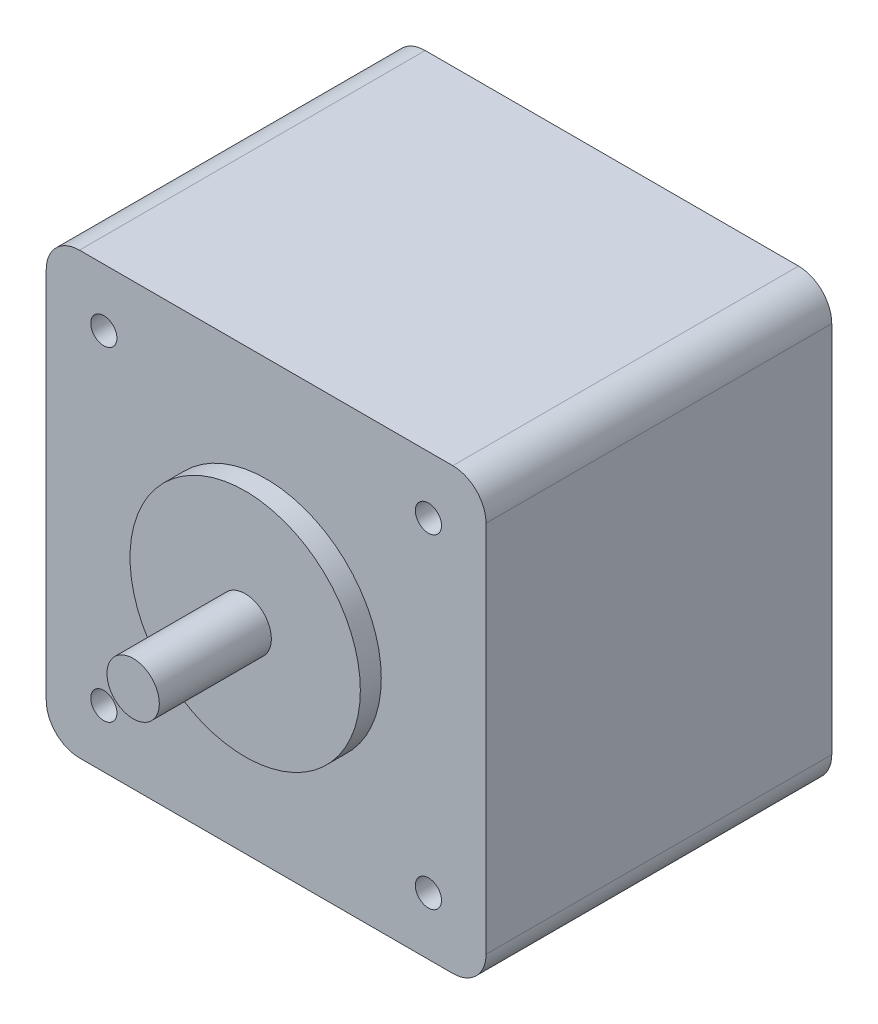
from build123d import *

# Parameters (mm, degrees)
SKETCH1_W                 = 42
SKETCH1_H                 = 42
BOSS_EXTRUDE1_DEPTH       = 33.02
M3X0_5_TAPPED_HOLE1_D     = 2.5
M3X0_5_TAPPED_HOLE1_DEPTH = 7.5
M3X0_5_TAPPED_HOLE1_TIP   = 0.751075774
FILLET1_R                 = 3.175


with BuildPart() as part:
    # Sketch1 → Boss-Extrude1 (new body)
    with BuildSketch(Plane.XY.offset(33.02)):
        Rectangle(SKETCH1_W, SKETCH1_H)
    extrude(amount=-BOSS_EXTRUDE1_DEPTH)

    # Sketch6 → Revolve5 (revolve)
    with BuildSketch(Plane(origin=(0, 0, 0), x_dir=(1, 0, 0), z_dir=(0, 1, 0))):
        Polygon((10.9982, -33.02), (0, -33.02), (0, -45.72), (2.5, -45.72), (2.5, -35.02), (10.9982, -35.02), align=None)
    revolve(axis=Axis((0, 0, 33.02), (0, 0, 1)))

    # M3x0.5 Tapped Hole1
    with Locations(Plane.XY.offset(33.02)):
        with Locations((-15.5, 15.5), (-15.5, -15.5), (15.5, -15.5), (15.5, 15.5)):
            Hole(M3X0_5_TAPPED_HOLE1_D / 2, depth=M3X0_5_TAPPED_HOLE1_DEPTH)
            with Locations((0, 0, -(M3X0_5_TAPPED_HOLE1_DEPTH + M3X0_5_TAPPED_HOLE1_TIP / 2))):  # 118° drill point
                Cone(0, M3X0_5_TAPPED_HOLE1_D / 2, M3X0_5_TAPPED_HOLE1_TIP, mode=Mode.SUBTRACT)

    # Fillet1
    fillet1_edges = [part.edges().sort_by_distance(p)[0] for p in [
        (-21, -21, 16.51),
        (-21, 21, 16.51),
        (21, 21, 16.51),
        (21, -21, 16.51),
    ]]
    fillet(fillet1_edges, radius=FILLET1_R)


solid = part.part
